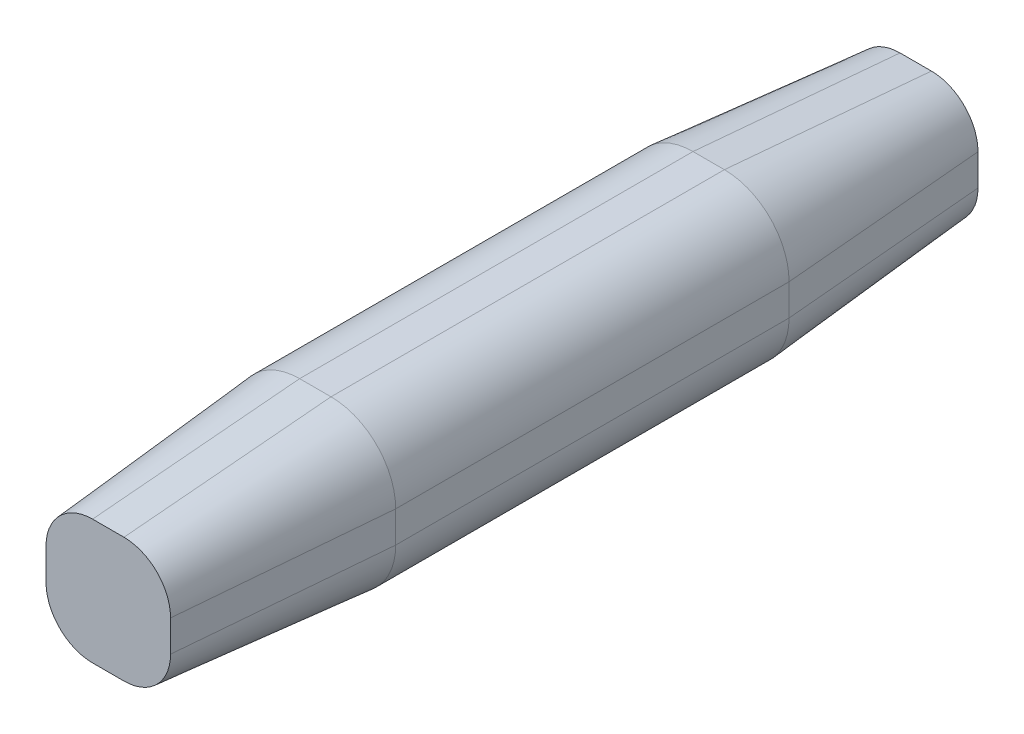
from build123d import *

# Parameters (mm, degrees)
BOSS_EXTRUDE1_DEPTH = 4.826
BOSS_EXTRUDE2_DEPTH = 5.08
BOSS_EXTRUDE2_TAPER = 5


with BuildPart() as part:
    # Sketch1 → Boss-Extrude1 (new body)
    with BuildSketch(Plane.XY):
        with BuildLine():
            Line((-0.385, -1.9725), (0.385, -1.9725))
            ThreePointArc((0.385, -1.9725), (1.507532015, -1.507532015), (1.9725, -0.385))
            Line((1.9725, -0.385), (1.9725, 0.385))
            ThreePointArc((1.9725, 0.385), (1.507532015, 1.507532015), (0.385, 1.9725))
            Line((0.385, 1.9725), (-0.385, 1.9725))
            ThreePointArc((-0.385, 1.9725), (-1.507532015, 1.507532015), (-1.9725, 0.385))
            Line((-1.9725, 0.385), (-1.9725, -0.385))
            ThreePointArc((-1.9725, -0.385), (-1.507532015, -1.507532015), (-0.385, -1.9725))
        make_face()
    boss_extrude1 = extrude(amount=BOSS_EXTRUDE1_DEPTH)

    # Sketch2 → Boss-Extrude2 (add)
    with BuildSketch(Plane.XY.offset(4.826)):
        with BuildLine():
            Line((1.9725, -0.385), (1.9725, 0.385))
            ThreePointArc((1.9725, 0.385), (1.507532015, 1.507532015), (0.385, 1.9725))
            Line((0.385, 1.9725), (-0.385, 1.9725))
            ThreePointArc((-0.385, 1.9725), (-1.507532015, 1.507532015), (-1.9725, 0.385))
            Line((-1.9725, 0.385), (-1.9725, -0.385))
            ThreePointArc((-1.9725, -0.385), (-1.507532015, -1.507532015), (-0.385, -1.9725))
            Line((-0.385, -1.9725), (0.385, -1.9725))
            ThreePointArc((0.385, -1.9725), (1.507532015, -1.507532015), (1.9725, -0.385))
        make_face()
    boss_extrude2 = extrude(amount=BOSS_EXTRUDE2_DEPTH, taper=BOSS_EXTRUDE2_TAPER)

    # Mirror1: Boss-Extrude1, Boss-Extrude2 across plane
    add(boss_extrude1.mirror(Plane.XY))
    add(boss_extrude2.mirror(Plane.XY))


solid = part.part
